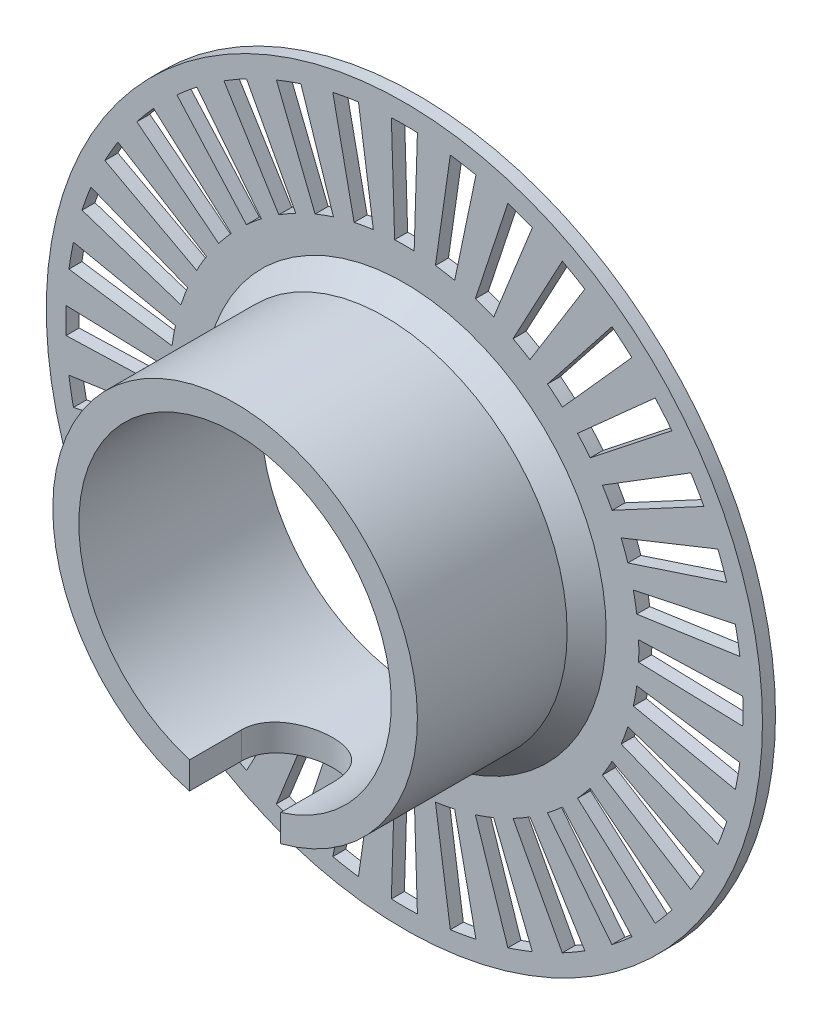
from build123d import *

# Parameters (mm, degrees)
SKETCH1_R           = 27.5
SKETCH1_R_2         = 12
BOSS_EXTRUDE1_DEPTH = 1
CUT_EXTRUDE1_DEPTH  = 1
CIRPATTERN1_COUNT   = 36
SKETCH4_R           = 14
SKETCH4_R_2         = 12
BOSS_EXTRUDE2_DEPTH = 13
CUT_EXTRUDE2_DEPTH  = 28.5
CHAMFER1_SIZE       = 1.5


with BuildPart() as part:
    # Sketch1 → Boss-Extrude1 (new body)
    with BuildSketch(Plane.XY):
        Circle(SKETCH1_R)
        Circle(SKETCH1_R_2, mode=Mode.SUBTRACT)
    extrude(amount=BOSS_EXTRUDE1_DEPTH)

    # Sketch3 → Cut-Extrude1 (cut)
    with BuildSketch(Plane.XY.offset(1)):
        with BuildLine():
            Line((-1, 25.980762114), (-0.75, 17.984368212))
            ThreePointArc((-0.75, 17.984368212), (0, 18), (0.75, 17.984368212))
            Line((0.75, 17.984368212), (1, 25.980762114))
            ThreePointArc((1, 25.980762114), (0, 26), (-1, 25.980762114))
        make_face()
    cut_extrude1 = extrude(amount=-CUT_EXTRUDE1_DEPTH, mode=Mode.SUBTRACT)

    # CirPattern1: Cut-Extrude1 ×36 about axis
    cirpattern1_axis = Axis((0, 0, 0), (0, 0, 1))
    for i in range(1, CIRPATTERN1_COUNT):
        add(cut_extrude1.rotate(cirpattern1_axis, i * 360 / CIRPATTERN1_COUNT), mode=Mode.SUBTRACT)

    # Sketch4 → Boss-Extrude2 (add)
    with BuildSketch(Plane.XY.offset(1)):
        Circle(SKETCH4_R)
        Circle(SKETCH4_R_2, mode=Mode.SUBTRACT)
    extrude(amount=BOSS_EXTRUDE2_DEPTH)

    # Sketch5 → Cut-Extrude2 (cut, through all)
    with BuildSketch(Plane(origin=(0, 0, 0), x_dir=(1, 0, 0), z_dir=(0, 1, 0))):
        with BuildLine():
            Line((-3.5, -10), (-3.5, -14))
            Line((-3.5, -14), (3.5, -14))
            Line((3.5, -14), (3.5, -10))
            ThreePointArc((3.5, -10), (0, -6.5), (-3.5, -10))
        make_face()
    extrude(amount=-CUT_EXTRUDE2_DEPTH, mode=Mode.SUBTRACT)

    # Chamfer1
    chamfer1_edges = [part.edges().sort_by_distance(p)[0] for p in [
        (-14, 0, 1),
    ]]
    chamfer(chamfer1_edges, length=CHAMFER1_SIZE)


solid = part.part
